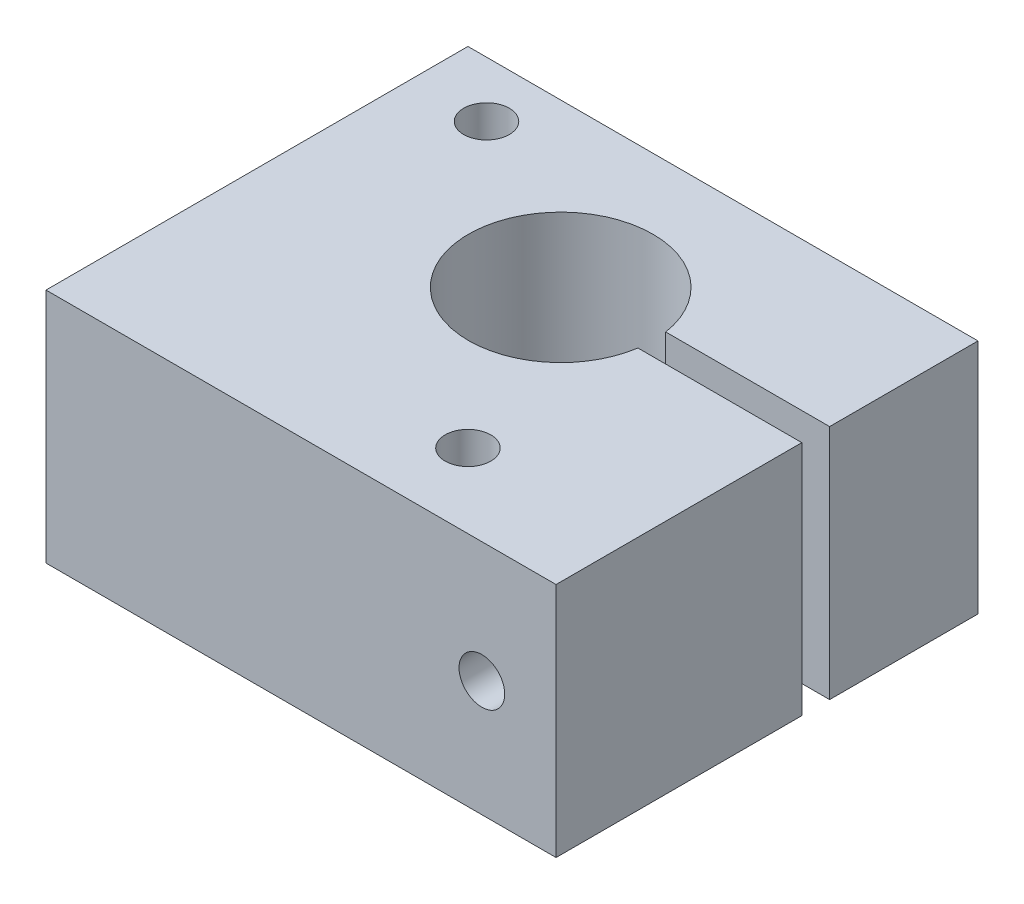
from build123d import *

# Parameters (mm, degrees)
SKETCH1_W           = 27.94
SKETCH1_H           = 23.114
BOSS_EXTRUDE1_DEPTH = 12.954
SKETCH2_R           = 5.05
CUT_EXTRUDE1_DEPTH  = 13.954
SKETCH3_W           = 13.97
SKETCH3_H           = 1.524
CUT_EXTRUDE2_DEPTH  = 13.954
SKETCH4_R           = 1.25
CUT_EXTRUDE3_DEPTH  = 13.954
SKETCH5_R           = 3.048
CUT_EXTRUDE4_DEPTH  = 4.318
CUT_EXTRUDE5_REACH  = 20.796
SKETCH6_R           = 1.7
SKETCH7_R           = 1.25
CUT_EXTRUDE6_DEPTH  = 19.796


with BuildPart() as part:
    # Sketch1 → Boss-Extrude1 (new body)
    with BuildSketch(Plane(origin=(0, 0, 0), x_dir=(1, 0, 0), z_dir=(0, 1, 0))):
        Rectangle(SKETCH1_W, SKETCH1_H)
    extrude(amount=BOSS_EXTRUDE1_DEPTH)

    # Sketch2 → Cut-Extrude1 (cut, through all)
    with BuildSketch(Plane(origin=(0, 12.954, 0), x_dir=(1, 0, 0), z_dir=(0, 1, 0))):
        with Locations((0, 2.667)):
            Circle(SKETCH2_R)
    extrude(amount=-CUT_EXTRUDE1_DEPTH, mode=Mode.SUBTRACT)

    # Sketch3 → Cut-Extrude2 (cut, through all)
    with BuildSketch(Plane(origin=(0, 12.954, 0), x_dir=(1, 0, 0), z_dir=(0, 1, 0))):
        with Locations((6.985, 2.667)):
            Rectangle(SKETCH3_W, SKETCH3_H)
    extrude(amount=-CUT_EXTRUDE2_DEPTH, mode=Mode.SUBTRACT)

    # Sketch4 → Cut-Extrude3 (cut, through all)
    with BuildSketch(Plane(origin=(0, 12.954, 0), x_dir=(1, 0, 0), z_dir=(0, 1, 0))):
        with Locations((-9.906, 8.509)):
            Circle(SKETCH4_R)
        with Locations((5.08, -7.493)):
            Circle(SKETCH4_R)
    extrude(amount=-CUT_EXTRUDE3_DEPTH, mode=Mode.SUBTRACT)

    # Sketch5 → Cut-Extrude4 (cut)
    with BuildSketch(Plane(origin=(0, 0, -11.557), x_dir=(-1, 0, 0), z_dir=(0, 0, -1))):
        with Locations((-9.906, 6.35)):
            Circle(SKETCH5_R)
    extrude(amount=-CUT_EXTRUDE4_DEPTH, mode=Mode.SUBTRACT)

    # Sketch6 → Cut-Extrude5 (cut, up to next)
    with BuildSketch(Plane(origin=(0, 0, -7.239), x_dir=(-1, 0, 0), z_dir=(0, 0, -1)), mode=Mode.PRIVATE) as cut_extrude5_sk1:
        with Locations((-9.906, 6.35)):
            Circle(SKETCH6_R)
    cut_extrude5_tool1 = extrude(cut_extrude5_sk1.sketch, amount=-CUT_EXTRUDE5_REACH, mode=Mode.PRIVATE) & part.part
    add(cut_extrude5_tool1.solids().sort_by_distance((9.906, 6.35, -7.239))[0], mode=Mode.SUBTRACT)

    # Sketch7 → Cut-Extrude6 (cut, through all)
    with BuildSketch(Plane(origin=(0, 0, -7.239), x_dir=(-1, 0, 0), z_dir=(0, 0, -1))):
        with Locations((-9.906, 6.35)):
            Circle(SKETCH7_R)
    extrude(amount=-CUT_EXTRUDE6_DEPTH, mode=Mode.SUBTRACT)


solid = part.part
